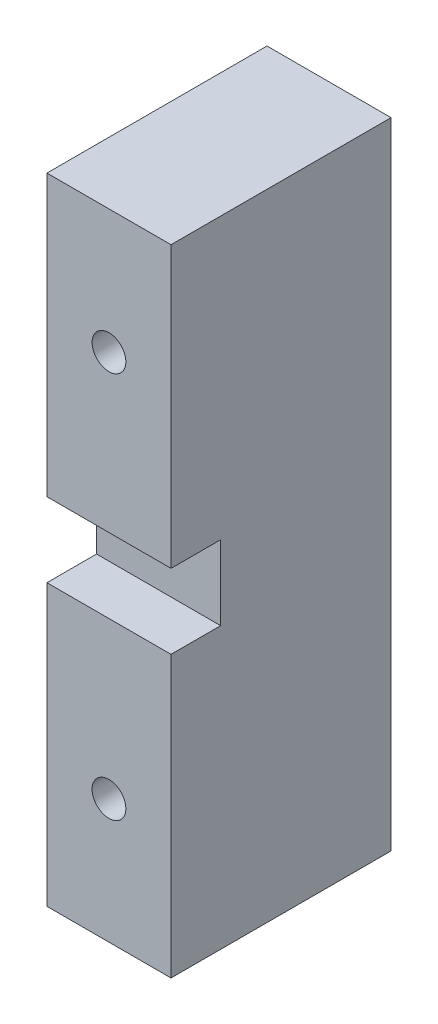
from build123d import *

# Parameters (mm, degrees)
ESBO_O1_W                   = 22.5248
ESBO_O1_H                   = 65
RESSALTO_EXTRUS_O1_DEPTH    = 12.7
ESBO_O2_W                   = 5.08
ESBO_O2_H                   = 7.62
CORTE_EXTRUS_O1_DEPTH       = 13.7
FURO_COM_FOLGA_DE_M31_D     = 3.4544
FURO_COM_FOLGA_DE_M31_DEPTH = 22.5248


with BuildPart() as part:
    # Esboço1 → Ressalto-extrusão1 (new body)
    with BuildSketch(Plane(origin=(12.7, 0, 0), x_dir=(0, 0, -1), z_dir=(1, 0, 0))):
        with Locations((-11.2624, 32.5)):
            Rectangle(ESBO_O1_W, ESBO_O1_H)
    extrude(amount=-RESSALTO_EXTRUS_O1_DEPTH)

    # Esboço2 → Corte-extrusão1 (cut, through all)
    with BuildSketch(Plane.ZY):
        with Locations((19.9848, 32.5)):
            Rectangle(ESBO_O2_W, ESBO_O2_H)
    extrude(amount=-CORTE_EXTRUS_O1_DEPTH, mode=Mode.SUBTRACT)

    # Furo com folga de M31
    with Locations(Plane(origin=(0, 0, 0), x_dir=(-1, 0, 0), z_dir=(0, 0, -1))):
        with Locations((-6.35, 12.7), (-6.35, 52.3)):
            Hole(FURO_COM_FOLGA_DE_M31_D / 2, depth=FURO_COM_FOLGA_DE_M31_DEPTH)


solid = part.part
